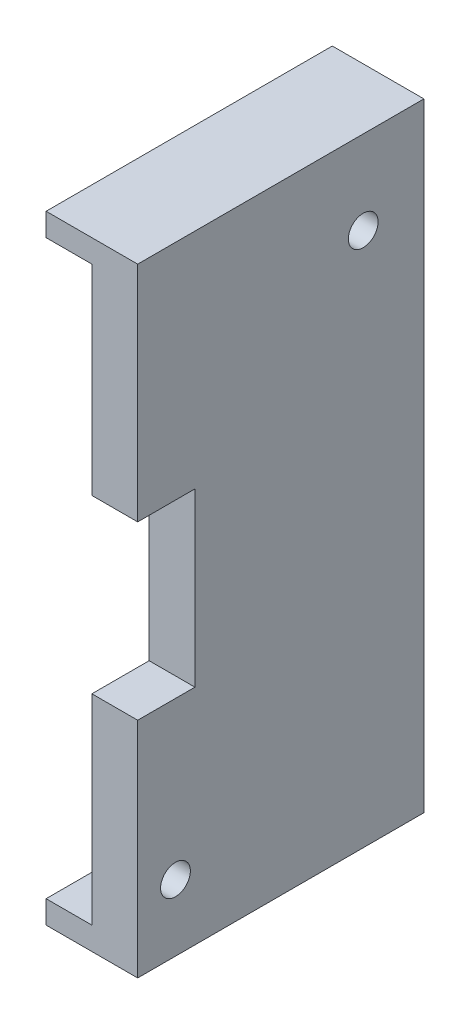
from build123d import *

# Parameters (mm, degrees)
SKETCH_13_W               = 25
SKETCH_13_H               = 54
EXTRUDE_6_DEPTH           = 3
EXTRUDE_6_DEPTH_BACK      = 5
SKETCH_16_W               = 22
SKETCH_16_H               = 50
CUT_EXTRUDE_9_DEPTH       = 25
SKETCH_17_W               = 5
SKETCH_17_H               = 15
CUT_EXTRUDE_10_DEPTH      = 30
SKETCH_23_R               = 1.3
CUT_EXTRUDE_11_DEPTH      = 30
CUT_EXTRUDE_11_DEPTH_BACK = 1


with BuildPart() as part:
    # Sketch 13 → Extrude 6 (new body, two sides)
    with BuildSketch(Plane(origin=(95, 0, 0), x_dir=(0, 0, -1), z_dir=(1, 0, 0))) as extrude_6_sk:
        with Locations((112.5, -3)):
            Rectangle(SKETCH_13_W, SKETCH_13_H)
    extrude(amount=EXTRUDE_6_DEPTH)
    extrude(extrude_6_sk.sketch, amount=-EXTRUDE_6_DEPTH_BACK)

    # Sketch 16 → Cut-Extrude 9 (cut)
    with BuildSketch(Plane(origin=(69, 0, 0), x_dir=(0, 0, -1), z_dir=(1, 0, 0))):
        with Locations((111, -3)):
            Rectangle(SKETCH_16_W, SKETCH_16_H)
    extrude(amount=CUT_EXTRUDE_9_DEPTH, mode=Mode.SUBTRACT)

    # Sketch 17 → Cut-Extrude 10 (cut, through all)
    with BuildSketch(Plane(origin=(69, 0, 0), x_dir=(0, 0, -1), z_dir=(1, 0, 0))):
        with Locations((102.5, -3)):
            Rectangle(SKETCH_17_W, SKETCH_17_H)
    extrude(amount=CUT_EXTRUDE_10_DEPTH, mode=Mode.SUBTRACT)

    # Sketch 23 → Cut-Extrude 11 (cut, two sides)
    with BuildSketch(Plane(origin=(69, 0, 0), x_dir=(0, 0, -1), z_dir=(1, 0, 0))) as cut_extrude_11_sk:
        with Locations((119.7, 16.7)):
            Circle(SKETCH_23_R)
        with Locations((103.3, -24.2)):
            Circle(SKETCH_23_R)
    extrude(amount=CUT_EXTRUDE_11_DEPTH, mode=Mode.SUBTRACT)
    extrude(cut_extrude_11_sk.sketch, amount=-CUT_EXTRUDE_11_DEPTH_BACK, mode=Mode.SUBTRACT)


solid = part.part
